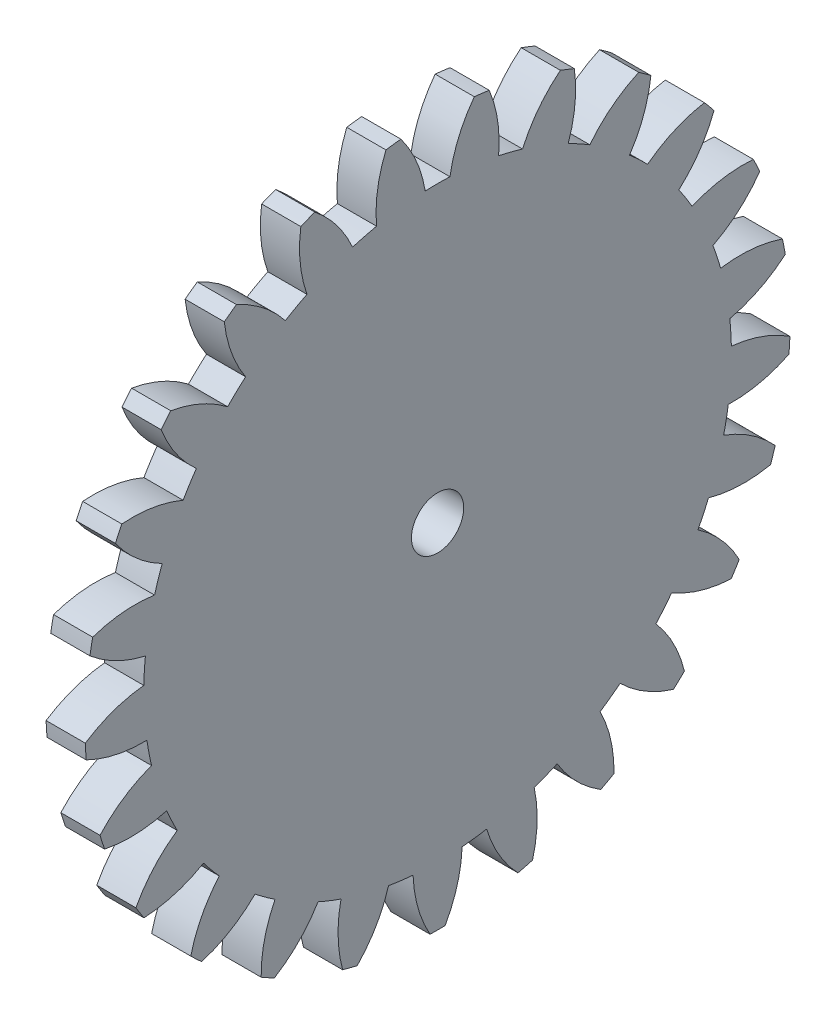
from build123d import *

# Parameters (mm, degrees)
BASPROSKE_W     = 3
BASPROSKE_H     = 27
TOOTHCUT_DEPTH  = 39.301436004
TEETHCUTS_COUNT = 25
TEETHCUTS_ANGLE = 345.6
BORSKE_R        = 2
BORE_DEPTH      = 50.0000508


with BuildPart() as part:
    # BasProSke → Base-Revolve (revolve)
    with BuildSketch(Plane(origin=(0, 0, 0), x_dir=(1, 0, 0), z_dir=(0, 1, 0)), mode=Mode.PRIVATE) as base_revolve_sk:
        with Locations((1.5, 13.5)):
            Rectangle(BASPROSKE_W, BASPROSKE_H)
    revolve(base_revolve_sk.sketch.rotate(Axis((-10, 0, 0), (1, 0, 0)), 180), axis=Axis((-10, 0, 0), (1, 0, 0)))

    # TooCutSke → ToothCut (cut, through all)
    with BuildSketch(Plane(origin=(0, 0, 0), x_dir=(0, 0, -1), z_dir=(1, 0, 0))):
        with BuildLine():
            ThreePointArc((0.946154762, 22.479096783), (0, 22.499), (-0.946154762, 22.479096783))
            ThreePointArc((-0.946154762, 22.479096783), (-1.62094792, 24.792268013), (-2.829470045, 26.876873784))
            ThreePointArc((-2.829470045, 26.876873784), (0, 27.0254), (2.829470045, 26.876873784))
            ThreePointArc((2.829470045, 26.876873784), (1.62094792, 24.792268013), (0.946154762, 22.479096783))
        make_face()
    toothcut = extrude(amount=TOOTHCUT_DEPTH, mode=Mode.SUBTRACT)

    # TeethCuts: ToothCut ×25 about axis
    teethcuts_axis = Axis((-10, 0, 0), (1, 0, 0))
    for i in range(1, TEETHCUTS_COUNT):
        add(toothcut.rotate(teethcuts_axis, i * TEETHCUTS_ANGLE / (TEETHCUTS_COUNT - 1)), mode=Mode.SUBTRACT)

    # BorSke → Bore (cut, symmetric)
    with BuildSketch(Plane(origin=(0, 0, 0), x_dir=(0, 0, -1), z_dir=(1, 0, 0))):
        with Locations(Location((0, 0, 0), (0, 0, 180))):
            Circle(BORSKE_R)
    extrude(amount=BORE_DEPTH, both=True, mode=Mode.SUBTRACT)


solid = part.part
